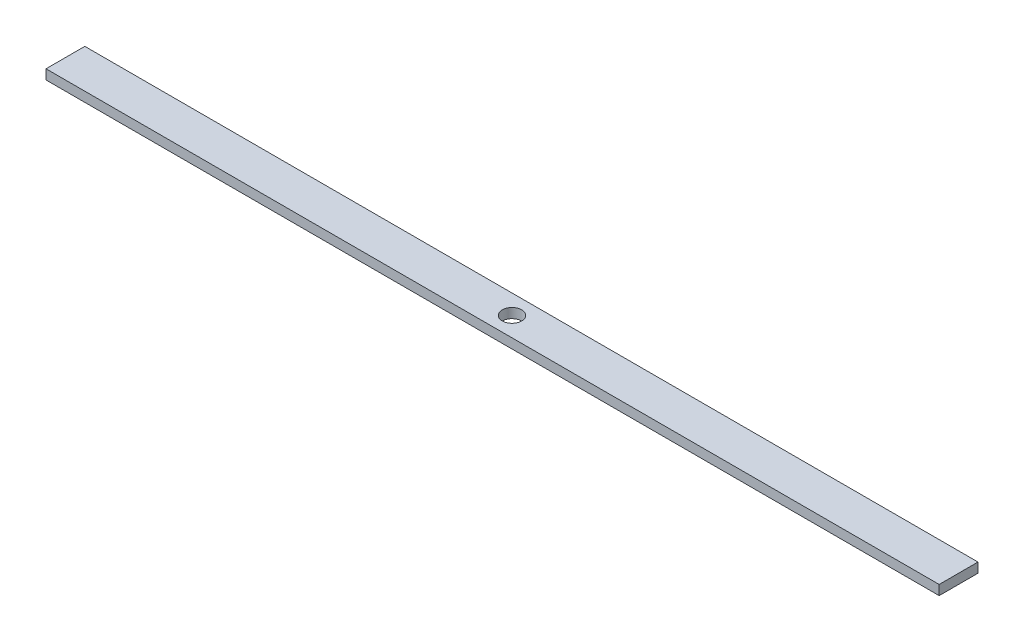
from build123d import *

# Parameters (mm, degrees)
SKETCH1_W           = 584.2
SKETCH1_H           = 25.4
SKETCH1_R           = 6.35
BOSS_EXTRUDE1_DEPTH = 6.35


with BuildPart() as part:
    # Sketch1 → Boss-Extrude1 (new body)
    with BuildSketch(Plane(origin=(0, 0, 0), x_dir=(1, 0, 0), z_dir=(0, 1, 0))):
        Rectangle(SKETCH1_W, SKETCH1_H)
        Circle(SKETCH1_R, mode=Mode.SUBTRACT)
    extrude(amount=BOSS_EXTRUDE1_DEPTH)


solid = part.part
